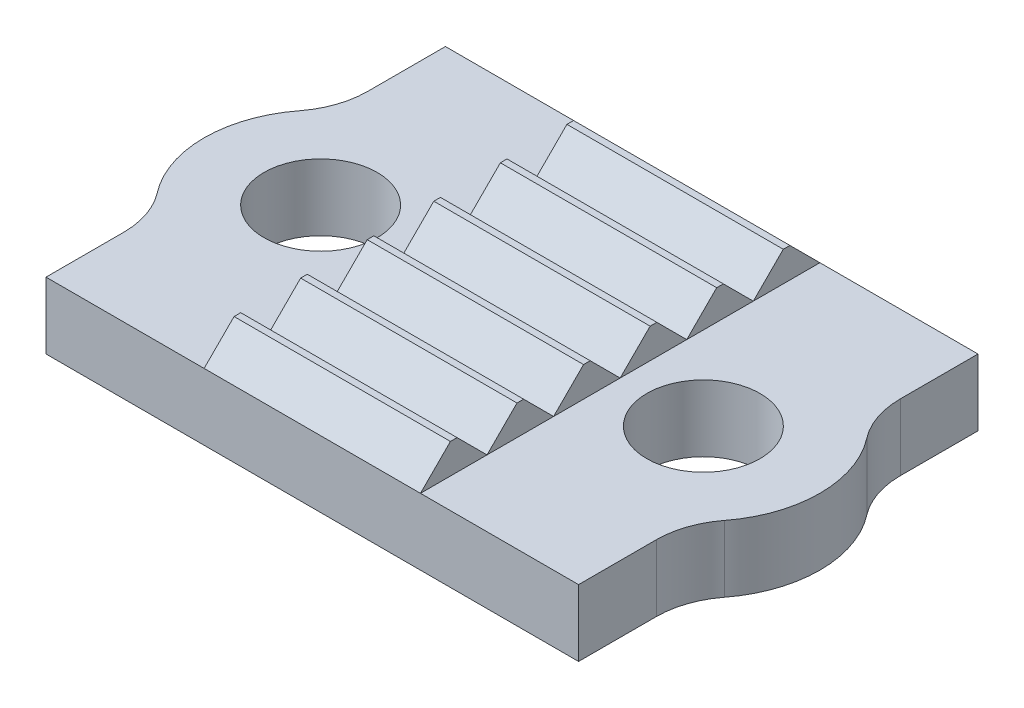
from build123d import *

# Parameters (mm, degrees)
CROQUIS1_R              = 1.7
SALIENTE_EXTRUIR1_DEPTH = 2
SALIENTE_EXTRUIR2_DEPTH = 6.5
MATRIZL1_COUNT          = 6
MATRIZL1_PITCH          = 2


with BuildPart() as part:
    # Croquis1 → Saliente-Extruir1 (new body)
    with BuildSketch(Plane(origin=(0, 0, 0), x_dir=(1, 0, 0), z_dir=(0, 1, 0))):
        with BuildLine():
            Line((-8, 6), (8, 6))
            Line((8, 6), (8, 3.665719575))
            ThreePointArc((8, 3.665719575), (8.133788189, 2.858848044), (8.520833333, 2.138336419))
            ThreePointArc((8.520833333, 2.138336419), (9.25, 0), (8.520833333, -2.138336419))
            ThreePointArc((8.520833333, -2.138336419), (8.133788189, -2.858848044), (8, -3.665719575))
            Line((8, -3.665719575), (8, -6))
            Line((8, -6), (-8, -6))
            Line((-8, -6), (-8, -3.665719575))
            ThreePointArc((-8, -3.665719575), (-8.133788189, -2.858848044), (-8.520833333, -2.138336419))
            ThreePointArc((-8.520833333, -2.138336419), (-9.25, 0), (-8.520833333, 2.138336419))
            ThreePointArc((-8.520833333, 2.138336419), (-8.133788189, 2.858848044), (-8, 3.665719575))
            Line((-8, 3.665719575), (-8, 6))
        make_face()
        with Locations((5.75, 0)):
            Circle(CROQUIS1_R, mode=Mode.SUBTRACT)
        with Locations((-5.75, 0)):
            Circle(CROQUIS1_R, mode=Mode.SUBTRACT)
    extrude(amount=SALIENTE_EXTRUIR1_DEPTH)

    # Croquis4 → Saliente-Extruir2 (add)
    with BuildSketch(Plane(origin=(3.25, 0, 0), x_dir=(0, 0, -1), z_dir=(1, 0, 0))):
        Polygon((-6, 2), (-4, 2), (-4.9, 2.9), (-5.1, 2.9), align=None)
    saliente_extruir2 = extrude(amount=-SALIENTE_EXTRUIR2_DEPTH)

    # MatrizL1: Saliente-Extruir2 ×6
    with Locations(*[(0, 0, -i * MATRIZL1_PITCH) for i in range(1, MATRIZL1_COUNT)]):
        add(saliente_extruir2)


solid = part.part
